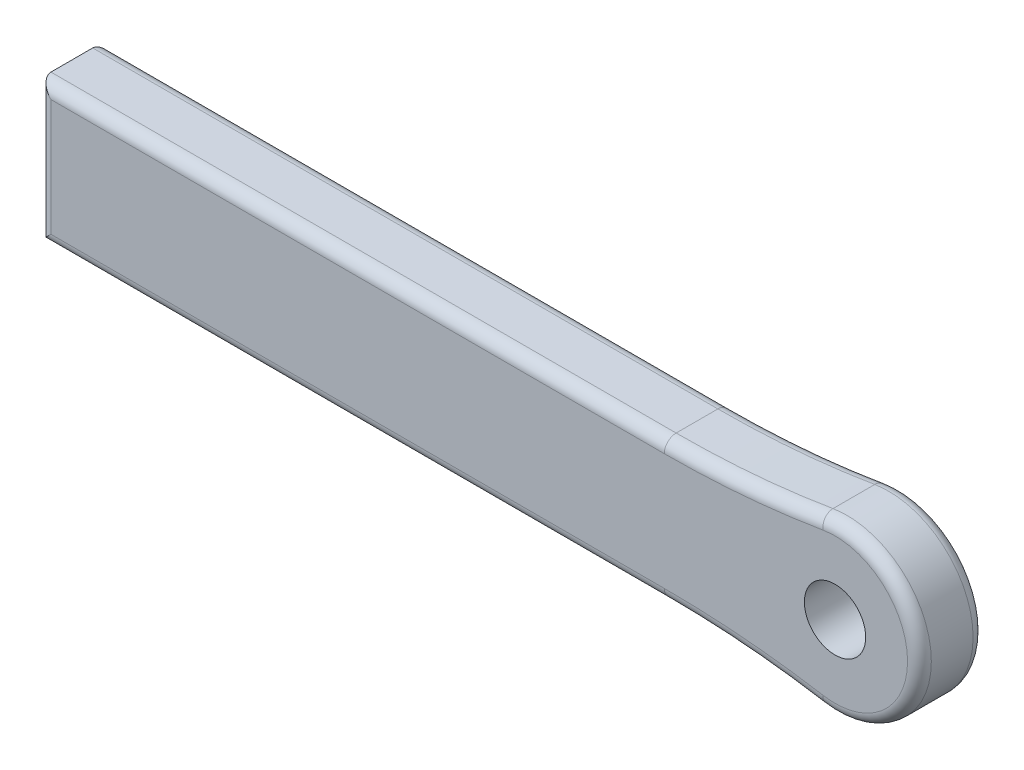
from build123d import *

# Parameters (mm, degrees)
BOSS_EXTRUDE1_DEPTH      = 14
FILLET1_R                = 2.54
FILLET2_R                = 2.54
F_9_16_18_TAPPED_HOLE1_D = 13.09624


with BuildPart() as part:
    # Sketch1 → Boss-Extrude1 (new body)
    with BuildSketch(Plane.XY):
        with BuildLine():
            Line((-80, -15), (53.524252006, -15))
            ThreePointArc((53.524252006, -15), (70.333541706, -15.696449958), (87.02760671, -17.78102579))
            ThreePointArc((87.02760671, -17.78102579), (108.027756377, 0), (87.02760671, 17.78102579))
            ThreePointArc((87.02760671, 17.78102579), (70.333541706, 15.696449958), (53.524252006, 15))
            Line((53.524252006, 15), (-80, 15))
            Line((-80, 15), (-80, -15))
        make_face()
    extrude(amount=BOSS_EXTRUDE1_DEPTH)

    # Fillet1
    fillet1_edges = [part.edges().sort_by_distance(p)[0] for p in [
        (70.333541706, -15.696449958, 14),
        (108.027756377, 0, 14),
        (70.333541706, 15.696449958, 14),
        (-13.237873997, 15, 14),
        (-80, 0, 14),
        (-13.237873997, -15, 14),
    ]]
    fillet(fillet1_edges, radius=FILLET1_R)

    # Fillet2
    fillet2_edges = [part.edges().sort_by_distance(p)[0] for p in [
        (-13.237873997, 15, 0),
        (70.333541706, 15.696449958, 0),
        (108.027756377, 0, 0),
        (70.333541706, -15.696449958, 0),
        (-13.237873997, -15, 0),
        (-80, 0, 0),
    ]]
    fillet(fillet2_edges, radius=FILLET2_R)

    # 9/16-18 Tapped Hole1 (through all)
    with Locations(Plane.XY.offset(14)):
        with Locations((90, 0)):
            Hole(F_9_16_18_TAPPED_HOLE1_D / 2)


solid = part.part
